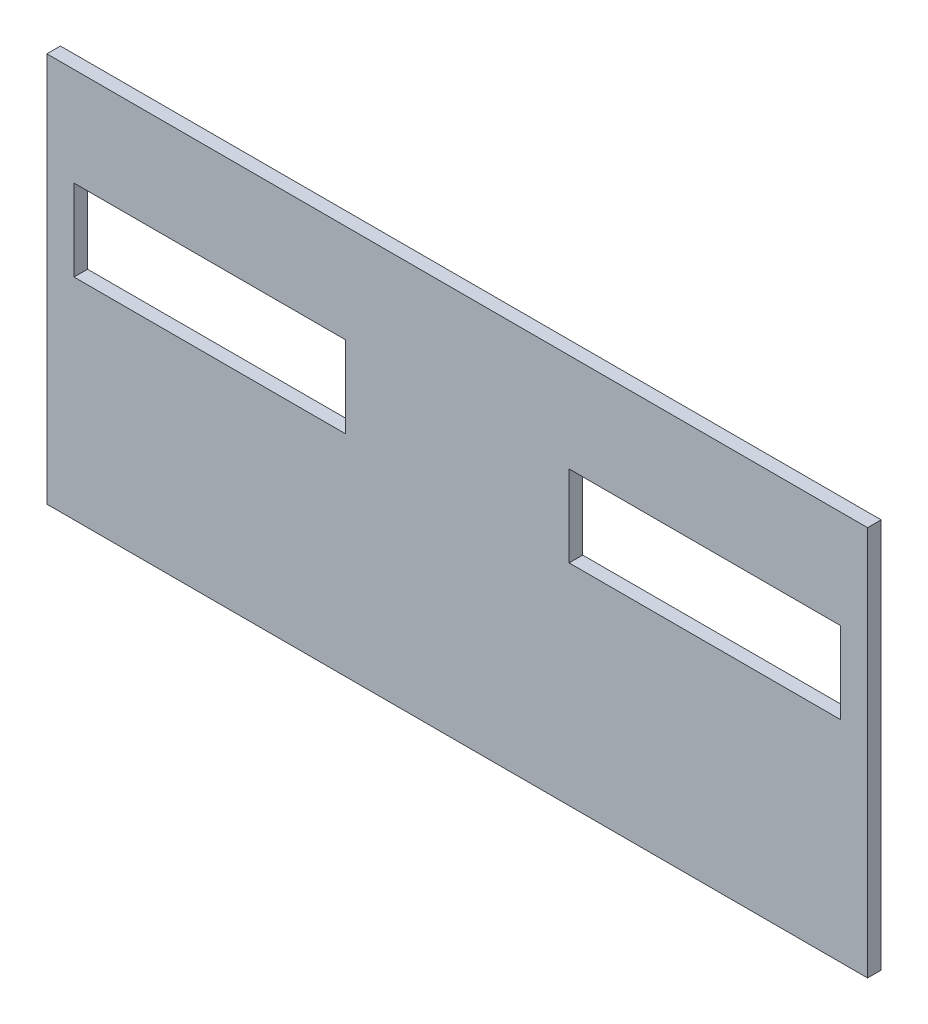
from build123d import *

# Parameters (mm, degrees)
SKETCH_1_W      = 242
SKETCH_1_H      = 115
SKETCH_1_W_2    = 80
SKETCH_1_H_2    = 24
EXTRUDE_1_DEPTH = 4


with BuildPart() as part:
    # 草图1 → 凸台-拉伸1 (new body)
    with BuildSketch(Plane.XY):
        with Locations((21.960072595, 8.709618875)):
            Rectangle(SKETCH_1_W, SKETCH_1_H)
        with Locations((-51.039927405, 25.209618875)):
            Rectangle(SKETCH_1_W_2, SKETCH_1_H_2, mode=Mode.SUBTRACT)
        with Locations((94.960072595, 25.209618875)):
            Rectangle(SKETCH_1_W_2, SKETCH_1_H_2, mode=Mode.SUBTRACT)
    extrude(amount=EXTRUDE_1_DEPTH)


solid = part.part
